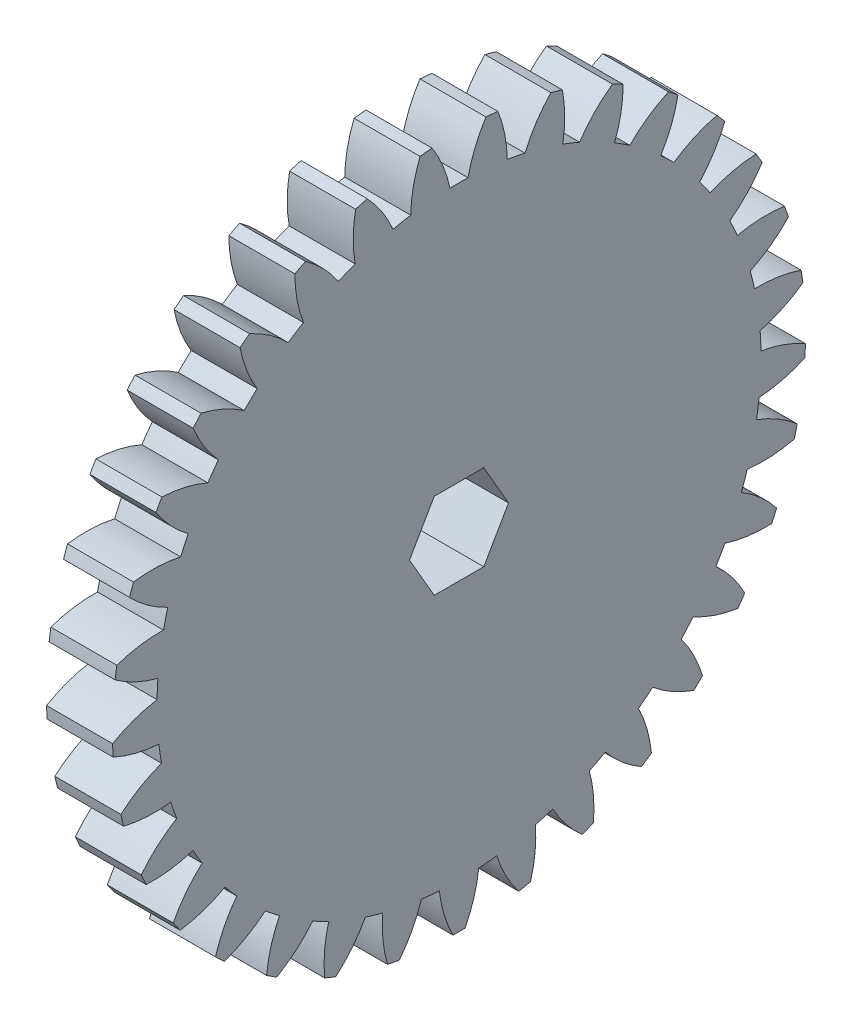
from build123d import *

# Parameters (mm, degrees)
BASPROSKE_W         = 5
BASPROSKE_H         = 26.25
TOOTHCUT_DEPTH      = 38.458310159
TEETHCUTS_COUNT     = 33
TEETHCUTS_ANGLE     = 349.090909091
BORE_DEPTH          = 50.0000508
BOSS_EXTRUDE1_DEPTH = 6


with BuildPart() as part:
    # BasProSke → Base-Revolve (revolve)
    with BuildSketch(Plane(origin=(0, 0, 0), x_dir=(1, 0, 0), z_dir=(0, 1, 0)), mode=Mode.PRIVATE) as base_revolve_sk:
        with Locations((2.5, 13.125)):
            Rectangle(BASPROSKE_W, BASPROSKE_H)
    revolve(base_revolve_sk.sketch.rotate(Axis((-10, 0, 0), (1, 0, 0)), 180), axis=Axis((-10, 0, 0), (1, 0, 0)))

    # TooCutSke → ToothCut (cut, through all)
    with BuildSketch(Plane(origin=(0, 0, 0), x_dir=(0, 0, -1), z_dir=(1, 0, 0))):
        with BuildLine():
            ThreePointArc((0.683690741, 22.863780155), (0, 22.874), (-0.683690741, 22.863780155))
            ThreePointArc((-0.683690741, 22.863780155), (-1.217783987, 24.592276227), (-2.057504394, 26.194719331))
            ThreePointArc((-2.057504394, 26.194719331), (0, 26.2754), (2.057504394, 26.194719331))
            ThreePointArc((2.057504394, 26.194719331), (1.217783987, 24.592276227), (0.683690741, 22.863780155))
        make_face()
    toothcut = extrude(amount=TOOTHCUT_DEPTH, mode=Mode.SUBTRACT)

    # TeethCuts: ToothCut ×33 about axis
    teethcuts_axis = Axis((-10, 0, 0), (1, 0, 0))
    for i in range(1, TEETHCUTS_COUNT):
        add(toothcut.rotate(teethcuts_axis, i * TEETHCUTS_ANGLE / (TEETHCUTS_COUNT - 1)), mode=Mode.SUBTRACT)

    # BorSke → Bore (cut, symmetric)
    with BuildSketch(Plane(origin=(0, 0, 0), x_dir=(0, 0, -1), z_dir=(1, 0, 0))):
        Polygon((-3.75, 0), (-1.875, -3.247595264), (1.875, -3.247595264), (3.75, 0), (1.875, 3.247595264), (-1.875, 3.247595264), align=None)
    extrude(amount=BORE_DEPTH, both=True, mode=Mode.SUBTRACT)

    # Sketch1 → Boss-Extrude1 (add)
    with BuildSketch(Plane.ZY):
        with BuildLine():
            ThreePointArc((0.186825137, -8.998060686), (1.087459558, -7.388027892), (0.875696025, -5.555405682))
            ThreePointArc((0.875696025, -5.555405682), (1.73791157, -5.348741832), (2.556932562, -5.009138816))
            ThreePointArc((2.556932562, -5.009138816), (3.462800574, -6.616232809), (5.13778266, -7.389397069))
            ThreePointArc((5.13778266, -7.389397069), (5.290067265, -7.281152932), (5.440072088, -7.169770943))
            ThreePointArc((5.440072088, -7.169770943), (5.222347109, -5.337847421), (3.973838504, -3.979696391))
            ThreePointArc((3.973838504, -3.979696391), (4.549911569, -3.305704242), (5.012899826, -2.549551171))
            ThreePointArc((5.012899826, -2.549551171), (6.690388591, -3.317261664), (8.499932112, -2.958234922))
            ThreePointArc((8.499932112, -2.958234922), (8.559508639, -2.781152931), (8.615396399, -2.602872386))
            ThreePointArc((8.615396399, -2.602872386), (7.362475561, -1.248790656), (5.554109736, -0.883878337))
            ThreePointArc((5.554109736, -0.883878337), (5.623999991, 1.7e-08), (5.554109736, 0.883878372))
            ThreePointArc((5.554109736, 0.883878372), (7.36247556, 1.248790692), (8.615396397, 2.602872424))
            ThreePointArc((8.615396397, 2.602872424), (8.559508637, 2.781152968), (8.49993211, 2.958234959))
            ThreePointArc((8.49993211, 2.958234959), (6.690388588, 3.3172617), (5.012899824, 2.549551205))
            ThreePointArc((5.012899824, 2.549551205), (4.549911566, 3.305704276), (3.9738385, 3.979696424))
            ThreePointArc((3.9738385, 3.979696424), (5.222347104, 5.337847455), (5.440072081, 7.169770978))
            ThreePointArc((5.440072081, 7.169770978), (5.290067259, 7.281152967), (5.137782653, 7.389397103))
            ThreePointArc((5.137782653, 7.389397103), (3.462800568, 6.616232842), (2.556932557, 5.009138848))
            ThreePointArc((2.556932557, 5.009138848), (1.737911565, 5.348741863), (0.87569602, 5.555405712))
            ThreePointArc((0.87569602, 5.555405712), (1.087459551, 7.388027922), (0.186825128, 8.998060715))
            ThreePointArc((0.186825128, 8.998060715), (-1.3e-08, 9.000000015), (-0.186825154, 8.998060715))
            ThreePointArc((-0.186825154, 8.998060715), (-1.087459575, 7.388027921), (-0.875696042, 5.555405712))
            ThreePointArc((-0.875696042, 5.555405712), (-1.737911587, 5.348741861), (-2.556932579, 5.009138846))
            ThreePointArc((-2.556932579, 5.009138846), (-3.462800592, 6.616232839), (-5.137782677, 7.389397098))
            ThreePointArc((-5.137782677, 7.389397098), (-5.290067283, 7.281152962), (-5.440072105, 7.169770972))
            ThreePointArc((-5.440072105, 7.169770972), (-5.222347126, 5.33784745), (-3.973838521, 3.97969642))
            ThreePointArc((-3.973838521, 3.97969642), (-4.549911586, 3.305704271), (-5.012899843, 2.5495512))
            ThreePointArc((-5.012899843, 2.5495512), (-6.690388608, 3.317261694), (-8.499932129, 2.958234951))
            ThreePointArc((-8.499932129, 2.958234951), (-8.559508657, 2.78115296), (-8.615396416, 2.602872416))
            ThreePointArc((-8.615396416, 2.602872416), (-7.362475579, 1.248790686), (-5.554109754, 0.883878367))
            ThreePointArc((-5.554109754, 0.883878367), (-5.624000009, 1.2e-08), (-5.554109753, -0.883878343))
            ThreePointArc((-5.554109753, -0.883878343), (-7.362475577, -1.248790663), (-8.615396414, -2.602872394))
            ThreePointArc((-8.615396414, -2.602872394), (-8.559508654, -2.781152939), (-8.499932127, -2.95823493))
            ThreePointArc((-8.499932127, -2.95823493), (-6.690388605, -3.317261671), (-5.012899841, -2.549551175))
            ThreePointArc((-5.012899841, -2.549551175), (-4.549911583, -3.305704246), (-3.973838517, -3.979696394))
            ThreePointArc((-3.973838517, -3.979696394), (-5.222347121, -5.337847426), (-5.440072098, -7.169770948))
            ThreePointArc((-5.440072098, -7.169770948), (-5.290067276, -7.281152937), (-5.13778267, -7.389397073))
            ThreePointArc((-5.13778267, -7.389397073), (-3.462800585, -6.616232813), (-2.556932575, -5.009138819))
            ThreePointArc((-2.556932575, -5.009138819), (-1.737911582, -5.348741834), (-0.875696037, -5.555405683))
            ThreePointArc((-0.875696037, -5.555405683), (-1.087459568, -7.388027893), (-0.186825145, -8.998060686))
            ThreePointArc((-0.186825145, -8.998060686), (-4e-09, -8.999999985), (0.186825137, -8.998060686))
        make_face()
        Polygon((3.75, 0), (1.875, 3.247595264), (-1.875, 3.247595264), (-3.75, 0), (-1.875, -3.247595264), (1.875, -3.247595264), align=None, mode=Mode.SUBTRACT)
    extrude(amount=BOSS_EXTRUDE1_DEPTH)


solid = part.part
